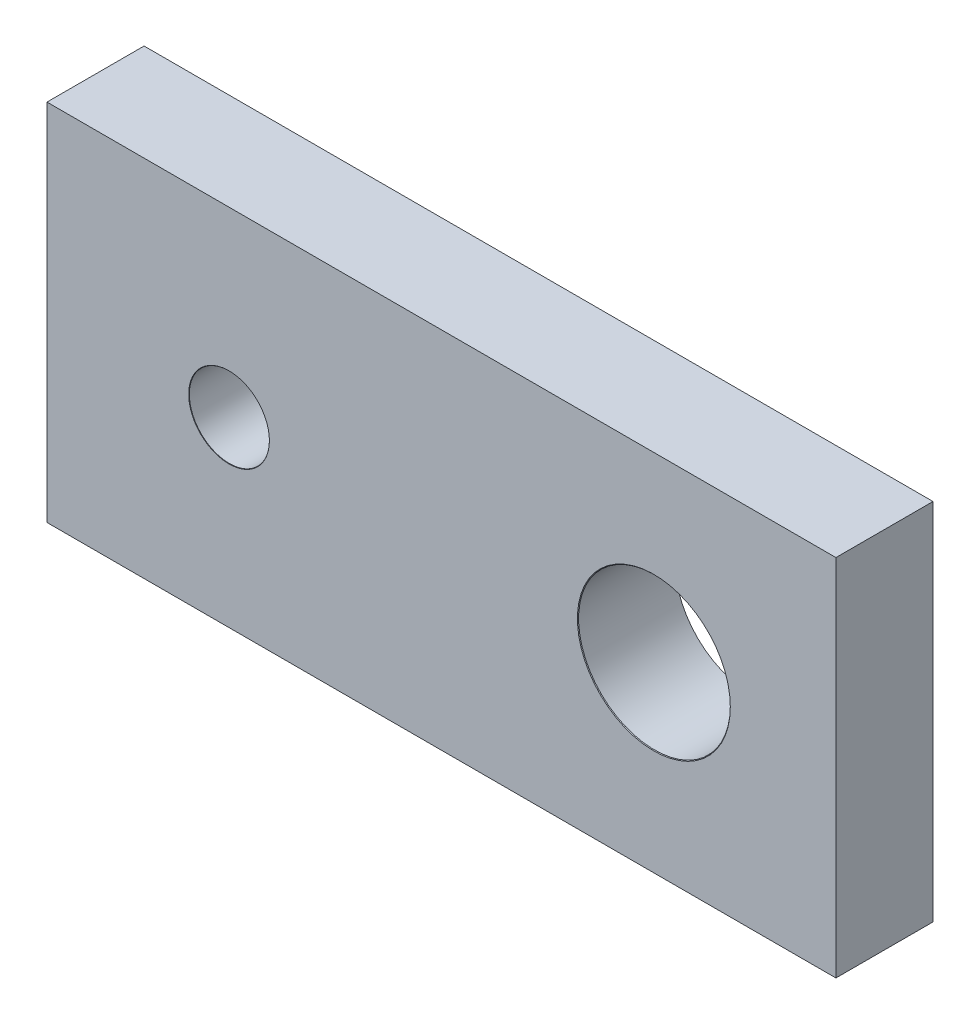
from build123d import *

# Parameters (mm, degrees)
SKETCH_1_W                   = 65
SKETCH_1_H                   = 30
EXTRUDE_1_DEPTH              = 8
HOLE_WIZARD_M6_1_D           = 6.6
HOLE_WIZARD_M6_1_DEPTH       = 20
HOLE_WIZARD_M6_1_CSINK_D     = 6.65
HOLE_WIZARD_M6_1_CSINK_ANGLE = 90
HOLE_WIZARD_M6_1_TIP         = 1.982840043
HOLE_WIZARD_M6_2_D           = 12.5
HOLE_WIZARD_M6_2_DEPTH       = 20
HOLE_WIZARD_M6_2_CSINK_D     = 12.6
HOLE_WIZARD_M6_2_CSINK_ANGLE = 90
HOLE_WIZARD_M6_2_TIP         = 3.755378869


with BuildPart() as part:
    # 草图1 → 凸台-拉伸1 (new body)
    with BuildSketch(Plane.XY):
        Rectangle(SKETCH_1_W, SKETCH_1_H)
    extrude(amount=EXTRUDE_1_DEPTH)

    # M6 间隙槽口1
    with Locations(Plane.XY.offset(8)):
        with Locations((-17.5, 0)):
            CounterSinkHole(HOLE_WIZARD_M6_1_D / 2, HOLE_WIZARD_M6_1_CSINK_D / 2, depth=HOLE_WIZARD_M6_1_DEPTH, counter_sink_angle=HOLE_WIZARD_M6_1_CSINK_ANGLE)
            with Locations((0, 0, -(HOLE_WIZARD_M6_1_DEPTH + HOLE_WIZARD_M6_1_TIP / 2))):  # 118° drill point
                Cone(0, HOLE_WIZARD_M6_1_D / 2, HOLE_WIZARD_M6_1_TIP, mode=Mode.SUBTRACT)

    # M6 间隙槽口2
    with Locations(Plane.XY.offset(8)):
        with Locations((17.5, 0)):
            CounterSinkHole(HOLE_WIZARD_M6_2_D / 2, HOLE_WIZARD_M6_2_CSINK_D / 2, depth=HOLE_WIZARD_M6_2_DEPTH, counter_sink_angle=HOLE_WIZARD_M6_2_CSINK_ANGLE)
            with Locations((0, 0, -(HOLE_WIZARD_M6_2_DEPTH + HOLE_WIZARD_M6_2_TIP / 2))):  # 118° drill point
                Cone(0, HOLE_WIZARD_M6_2_D / 2, HOLE_WIZARD_M6_2_TIP, mode=Mode.SUBTRACT)


solid = part.part
